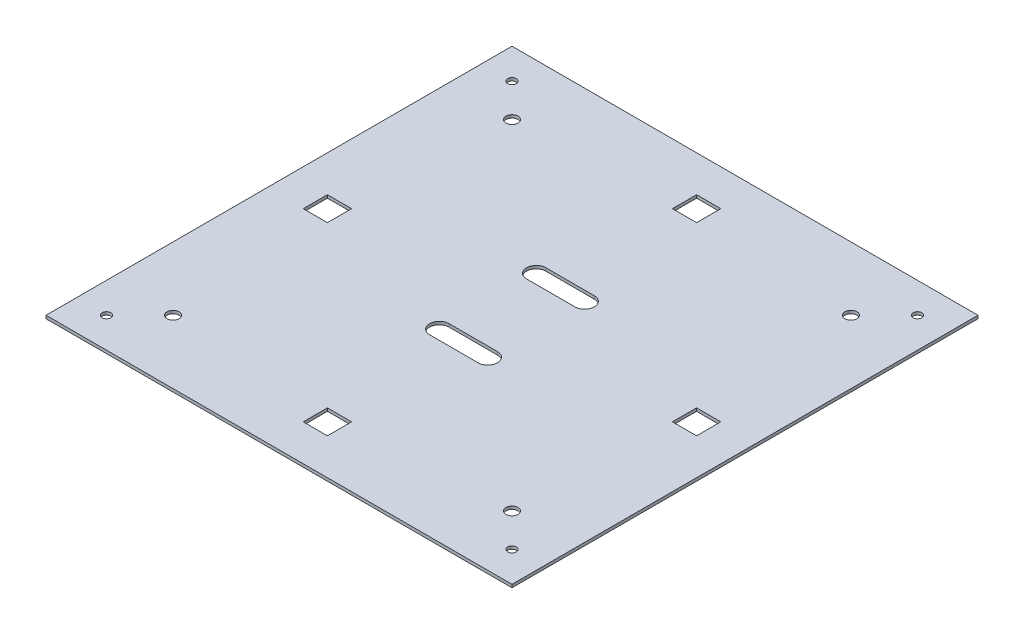
from build123d import *

# Parameters (mm, degrees)
SKETCH1_W                    = 244.475
SKETCH1_H                    = 244.475
MAIN_BODY_DEPTH              = 1.5875
SKETCH2_R                    = 3.175
SKETCH2_R_2                  = 2.286
SCREW_AND_STRING_HOLES_DEPTH = 2.5875
SKETCH4_W                    = 12.7
SKETCH4_H                    = 12.7
LED_HOLES_DEPTH              = 2.5875
EXTERNAL_CABLE_SLOTS_DEPTH   = 2.5875


with BuildPart() as part:
    # Sketch1 → Main Body (new body)
    with BuildSketch(Plane(origin=(0, 0, 0), x_dir=(1, 0, 0), z_dir=(0, 1, 0))):
        with Locations((122.2375, 122.2375)):
            Rectangle(SKETCH1_W, SKETCH1_H)
    extrude(amount=MAIN_BODY_DEPTH)

    # Sketch2 → Screw and String Holes (cut, through all)
    with BuildSketch(Plane(origin=(0, 1.5875, 0), x_dir=(1, 0, 0), z_dir=(0, 1, 0))):
        with Locations((211.1375, 33.3375)):
            Circle(SKETCH2_R)
        with Locations((33.3375, 33.3375)):
            Circle(SKETCH2_R)
        with Locations((33.3375, 211.1375)):
            Circle(SKETCH2_R)
        with Locations((211.1375, 211.1375)):
            Circle(SKETCH2_R)
        with Locations((228.6, 15.875)):
            Circle(SKETCH2_R_2)
        with Locations((15.875, 15.875)):
            Circle(SKETCH2_R_2)
        with Locations((15.875000001, 228.6)):
            Circle(SKETCH2_R_2)
        with Locations((228.6, 228.6)):
            Circle(SKETCH2_R_2)
    extrude(amount=-SCREW_AND_STRING_HOLES_DEPTH, mode=Mode.SUBTRACT)

    # Sketch4 → LED Holes (cut, through all)
    with BuildSketch(Plane(origin=(0, 1.5875, 0), x_dir=(1, 0, 0), z_dir=(0, 1, 0))):
        with Locations((122.2375, 25.4)):
            Rectangle(SKETCH4_W, SKETCH4_H)
        with Locations((25.4, 122.2375)):
            Rectangle(SKETCH4_W, SKETCH4_H)
        with Locations((122.2375, 219.075)):
            Rectangle(SKETCH4_W, SKETCH4_H)
        with Locations((219.075, 122.2375)):
            Rectangle(SKETCH4_W, SKETCH4_H)
    extrude(amount=-LED_HOLES_DEPTH, mode=Mode.SUBTRACT)

    # Sketch5 → External Cable Slots (cut, through all)
    with BuildSketch(Plane(origin=(0, 1.5875, 0), x_dir=(1, 0, 0), z_dir=(0, 1, 0))):
        with BuildLine():
            Line((109.5375, 101.9175), (134.9375, 101.9175))
            ThreePointArc((134.9375, 101.9175), (140.0175, 96.8375), (134.9375, 91.7575))
            Line((134.9375, 91.7575), (109.5375, 91.7575))
            ThreePointArc((109.5375, 91.7575), (104.4575, 96.8375), (109.5375, 101.9175))
        make_face()
        with BuildLine():
            Line((109.5375, 152.7175), (134.9375, 152.7175))
            ThreePointArc((134.9375, 152.7175), (140.0175, 147.6375), (134.9375, 142.5575))
            Line((134.9375, 142.5575), (109.5375, 142.5575))
            ThreePointArc((109.5375, 142.5575), (104.4575, 147.6375), (109.5375, 152.7175))
        make_face()
    extrude(amount=-EXTERNAL_CABLE_SLOTS_DEPTH, mode=Mode.SUBTRACT)


solid = part.part
